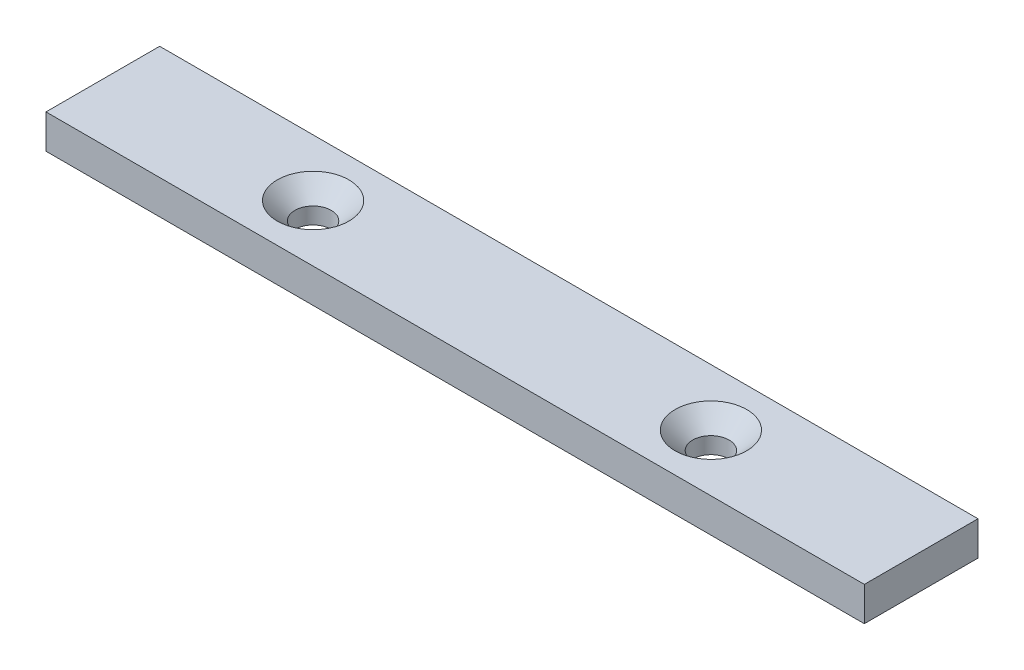
from build123d import *

# Parameters (mm, degrees)
SKETCH1_W           = 144
SKETCH1_H           = 20
BOSS_EXTRUDE1_DEPTH = 6
HOLE1_AT_2_COUNT    = 2
HOLE1_AT_2_PITCH    = 70


with BuildPart() as part:
    # Sketch1 → Boss-Extrude1 (new body)
    with BuildSketch(Plane(origin=(0, 0, 0), x_dir=(1, 0, 0), z_dir=(0, 1, 0))):
        Rectangle(SKETCH1_W, SKETCH1_H)
    extrude(amount=BOSS_EXTRUDE1_DEPTH)

    # Sketch3 → Hole1 (revolve, cut)
    with BuildSketch(Plane(origin=(-35, 6, 0), x_dir=(0, 0, 1), z_dir=(1, 0, 0))):
        Polygon((0, 0), (0, 6), (3.2, 6), (3.2, 3.1), (6.3, 0), align=None)
    hole1 = revolve(axis=Axis((-35, 20.308894879, 0), (0, -1, 0)), mode=Mode.SUBTRACT)

    # Hole1 at 2: Hole1 ×2
    with Locations(*[(i * HOLE1_AT_2_PITCH, 0, 0) for i in range(1, HOLE1_AT_2_COUNT)]):
        add(hole1, mode=Mode.SUBTRACT)


solid = part.part
